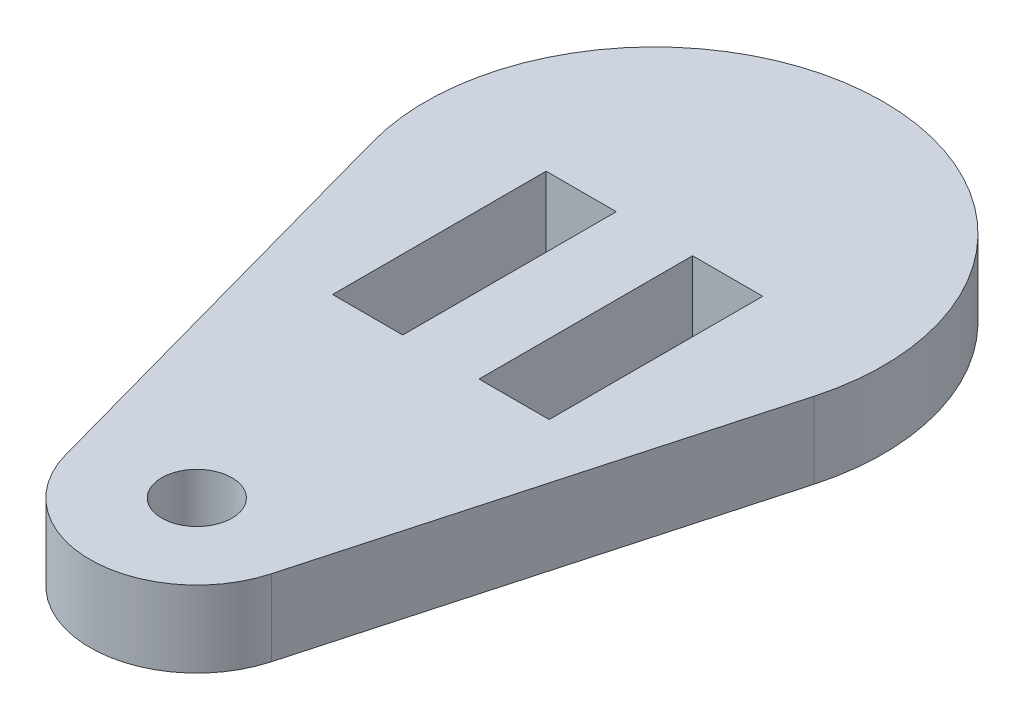
from build123d import *

# Parameters (mm, degrees)
SKETCH1_R           = 1.4605
BOSS_EXTRUDE1_DEPTH = 1.5875
CUT_EXTRUDE1_START  = -4.175
SKETCH2_W           = 2.921
SKETCH2_H           = 8.89
CUT_EXTRUDE1_DEPTH  = 5.175


with BuildPart() as part:
    # Sketch1 → Boss-Extrude1 (new body, symmetric)
    with BuildSketch(Plane(origin=(0, 0, 0), x_dir=(1, 0, 0), z_dir=(0, 1, 0))):
        with BuildLine():
            Line((4.284041303, -20.235333333), (9.180088507, -2.54))
            ThreePointArc((9.180088507, -2.54), (0, 9.525), (-9.180088507, -2.54))
            Line((-9.180088507, -2.54), (-4.284041303, -20.235333333))
            ThreePointArc((-4.284041303, -20.235333333), (0, -23.495), (4.284041303, -20.235333333))
        make_face()
        with Locations((0, -19.05)):
            Circle(SKETCH1_R, mode=Mode.SUBTRACT)
    extrude(amount=BOSS_EXTRUDE1_DEPTH, both=True)

    # Sketch2 → Cut-Extrude1 (cut)
    with BuildSketch(Plane(origin=(0, 1.5875, 0), x_dir=(1, 0, 0), z_dir=(0, 1, 0)).offset(CUT_EXTRUDE1_START)):
        with Locations((-3.048, -4.445)):
            Rectangle(SKETCH2_W, SKETCH2_H)
    cut_extrude1 = extrude(amount=CUT_EXTRUDE1_DEPTH, mode=Mode.SUBTRACT)

    # Mirror1: Cut-Extrude1 across plane
    add(cut_extrude1.mirror(Plane(origin=(0, 0, 0), x_dir=(0, 0, 1), z_dir=(1, 0, 0))), mode=Mode.SUBTRACT)


solid = part.part
